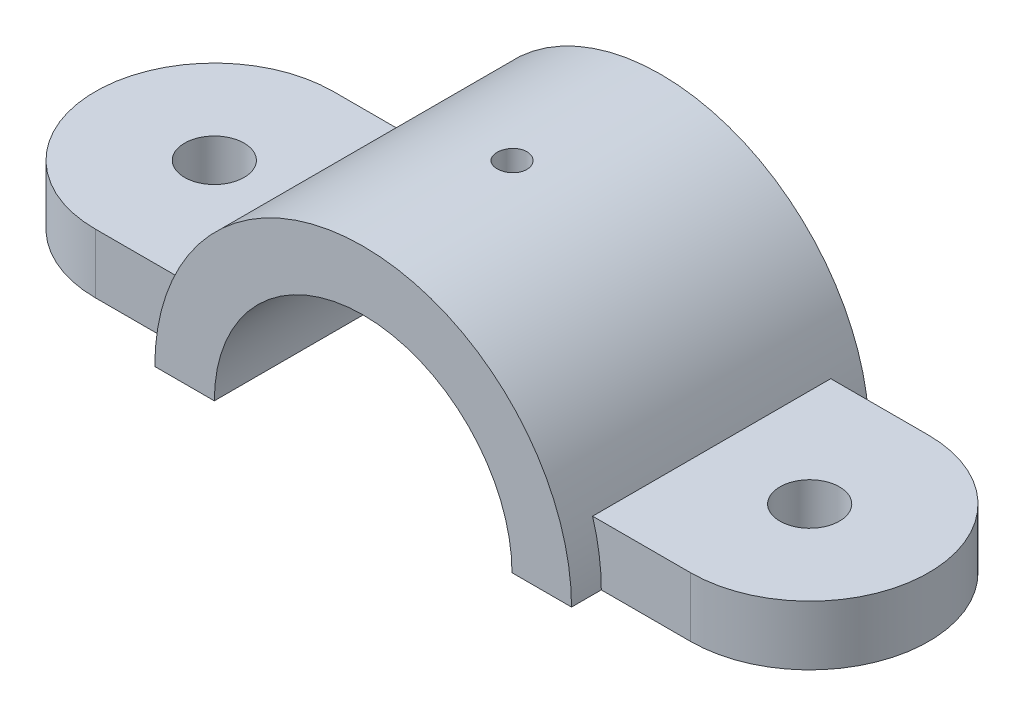
from build123d import *

# Parameters (mm, degrees)
SLOTSKETCH_R      = 6.35
SLOTEXTRUDE_DEPTH = 12.7
ARCEXTRUDE_DEPTH  = 31.75
CENTERDRILL_D     = 6.35
ARCPROFILE_DEPTH  = 64.5000001


with BuildPart() as part:
    # slotSketch → slotExtrude (new body)
    with BuildSketch(Plane(origin=(0, 0, 0), x_dir=(1, 0, 0), z_dir=(0, 1, 0))):
        with BuildLine():
            Line((-63.5, 25.4), (63.5, 25.4))
            ThreePointArc((63.5, 25.4), (88.9, 0), (63.5, -25.4))
            Line((63.5, -25.4), (-63.5, -25.4))
            ThreePointArc((-63.5, -25.4), (-88.9, 0), (-63.5, 25.4))
        make_face()
        with Locations(Location((63.5, 0, 0), (0, 0, 270))):  # turned: the seam where the file's is
            Circle(SLOTSKETCH_R, mode=Mode.SUBTRACT)
        with Locations(Location((-63.5, 0, 0), (0, 0, 90))):  # turned: the seam where the file's is
            Circle(SLOTSKETCH_R, mode=Mode.SUBTRACT)
    extrude(amount=SLOTEXTRUDE_DEPTH)

    # Sketch3 → arcExtrude (add, symmetric)
    with BuildSketch(Plane.XY):
        with BuildLine():
            Line((-44.45, 0), (44.45, 0))
            ThreePointArc((44.45, 0), (0, 44.45), (-44.45, 0))
        make_face()
    extrude(amount=ARCEXTRUDE_DEPTH, both=True)

    # centerDrill (through all)
    with Locations(Plane(origin=(0, 0, 0), x_dir=(-1, 0, 0), z_dir=(0, -1, 0))):
        with Locations((0, 0)):
            Hole(CENTERDRILL_D / 2)

    # Sketch7 → arcProfile (cut, through all)
    with BuildSketch(Plane.XY.offset(31.75)):
        with BuildLine():
            Line((-31.75, 0), (31.75, 0))
            ThreePointArc((31.75, 0), (0, 31.75), (-31.75, 0))
        make_face()
    extrude(amount=-ARCPROFILE_DEPTH, mode=Mode.SUBTRACT)


solid = part.part
